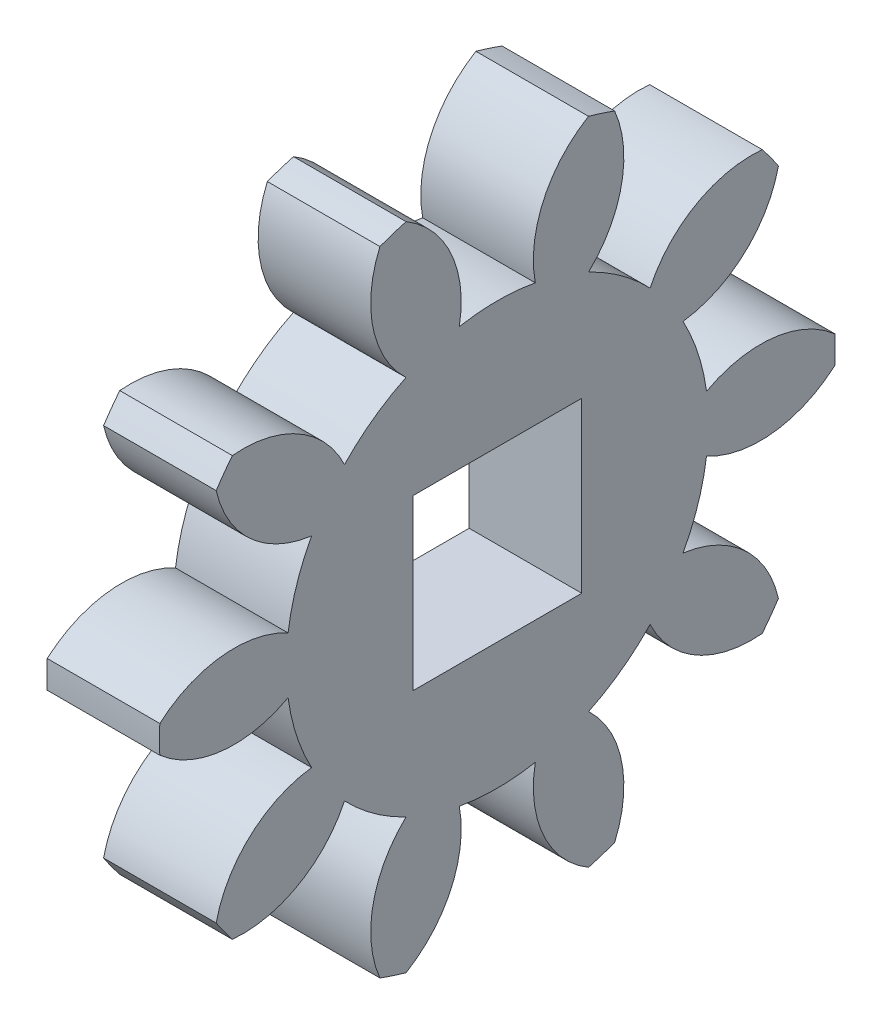
from build123d import *

# Parameters (mm, degrees)
BASPROSKE_W         = 4
BASPROSKE_H         = 12
TOOTHCUT_DEPTH      = 18.435595774
TEETHCUTS_COUNT     = 10
TEETHCUTS_ANGLE     = 324
BORSKE_R            = 1
BORE_DEPTH          = 50.0000508
SKETCH_1_W          = 6
SKETCH_1_H          = 6
CUT_EXTRUDE_2_DEPTH = 18.131831434


with BuildPart() as part:
    # BasProSke → Base-Revolve (revolve)
    with BuildSketch(Plane(origin=(0, 0, 0), x_dir=(1, 0, 0), z_dir=(0, 1, 0)), mode=Mode.PRIVATE) as base_revolve_sk:
        with Locations((2, 6)):
            Rectangle(BASPROSKE_W, BASPROSKE_H)
    revolve(base_revolve_sk.sketch.rotate(Axis((-10, 0, 0), (1, 0, 0)), 180), axis=Axis((-10, 0, 0), (1, 0, 0)))

    # TooCutSke → ToothCut (cut, through all)
    with BuildSketch(Plane(origin=(0, 0, 0), x_dir=(0, 0, -1), z_dir=(1, 0, 0))):
        with BuildLine():
            ThreePointArc((1.349961767, 7.376489967), (0, 7.499), (-1.349961767, 7.376489967))
            ThreePointArc((-1.349961767, 7.376489967), (-1.644412889, 9.779161882), (-3.270793922, 11.572041837))
            ThreePointArc((-3.270793922, 11.572041837), (0, 12.0254), (3.270793922, 11.572041837))
            ThreePointArc((3.270793922, 11.572041837), (1.644412889, 9.779161882), (1.349961767, 7.376489967))
        make_face()
    toothcut = extrude(amount=TOOTHCUT_DEPTH, mode=Mode.SUBTRACT)

    # TeethCuts: ToothCut ×10 about axis
    teethcuts_axis = Axis((-10, 0, 0), (1, 0, 0))
    for i in range(1, TEETHCUTS_COUNT):
        add(toothcut.rotate(teethcuts_axis, i * TEETHCUTS_ANGLE / (TEETHCUTS_COUNT - 1)), mode=Mode.SUBTRACT)

    # BorSke → Bore (cut, symmetric)
    with BuildSketch(Plane(origin=(0, 0, 0), x_dir=(0, 0, -1), z_dir=(1, 0, 0))):
        with Locations(Location((0, 0, 0), (0, 0, 180))):
            Circle(BORSKE_R)
    extrude(amount=BORE_DEPTH, both=True, mode=Mode.SUBTRACT)

    # 草图1 → 切除-拉伸2 (cut, through all)
    with BuildSketch(Plane.ZY):
        Rectangle(SKETCH_1_W, SKETCH_1_H)
    extrude(amount=-CUT_EXTRUDE_2_DEPTH, mode=Mode.SUBTRACT)


solid = part.part
